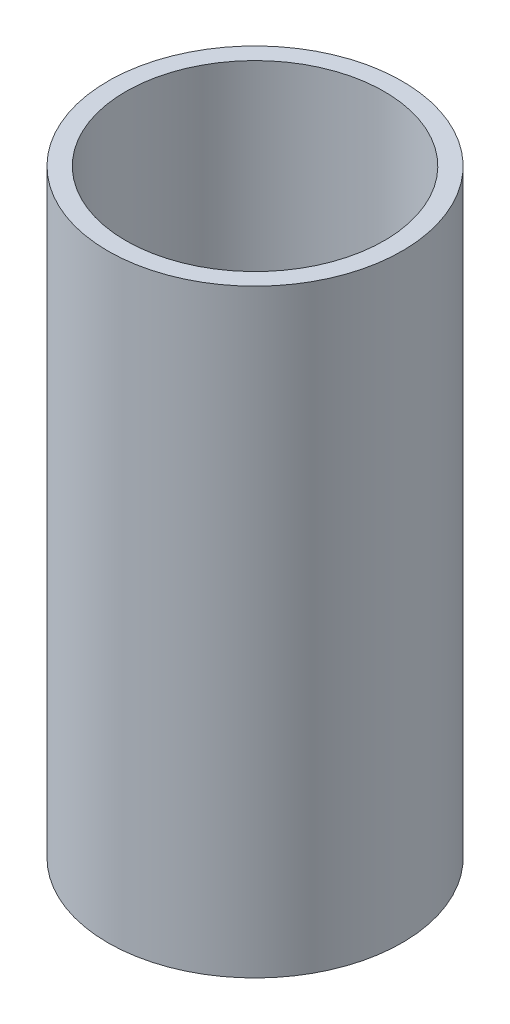
from build123d import *

# Parameters (mm, degrees)
SKETCH1_R           = 57.836986526
SKETCH1_R_2         = 50.8
BOSS_EXTRUDE1_DEPTH = 235.5


with BuildPart() as part:
    # Sketch1 → Boss-Extrude1 (new body)
    with BuildSketch(Plane(origin=(0, 0, 0), x_dir=(1, 0, 0), z_dir=(0, 1, 0))):
        Circle(SKETCH1_R)
        Circle(SKETCH1_R_2, mode=Mode.SUBTRACT)
    extrude(amount=BOSS_EXTRUDE1_DEPTH)


solid = part.part
